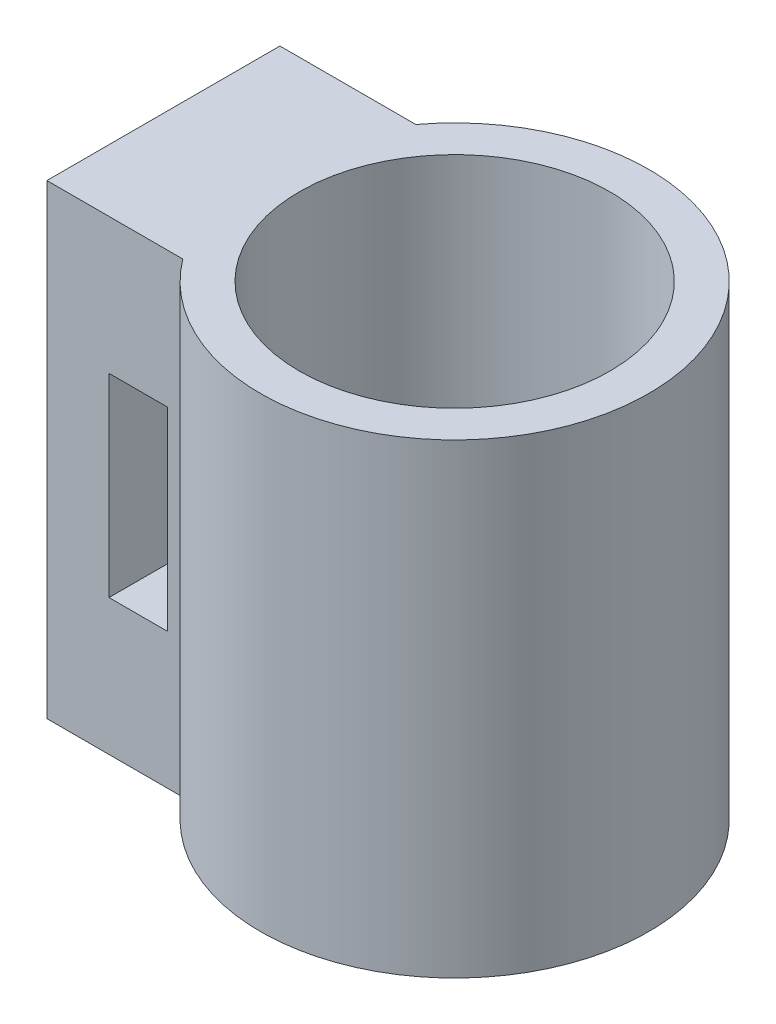
from build123d import *

# Parameters (mm, degrees)
BOSS_EXTRUDE1_DEPTH      = 6
BOSS_EXTRUDE1_DEPTH_BACK = 6
SKETCH1_R                = 4
SKETCH2_W                = 1.5
SKETCH2_H                = 5
CUT_EXTRUDE1_DEPTH       = 13.5


with BuildPart() as part:
    # Sketch1 → Boss-Extrude1 (new, two sides: drawn at the far end of the back side and taken through both)
    with BuildSketch(Plane(origin=(0, 0, 0), x_dir=(1, 0, 0), z_dir=(0, 1, 0)).offset(-BOSS_EXTRUDE1_DEPTH_BACK)):
        with BuildLine():
            Line((-4, 3), (-7.5, 3))
            Line((-7.5, 3), (-7.5, -3))
            Line((-7.5, -3), (-4, -3))
            ThreePointArc((-4, -3), (5, 0), (-4, 3))
        make_face()
        Circle(SKETCH1_R, mode=Mode.SUBTRACT)
    extrude(amount=BOSS_EXTRUDE1_DEPTH + BOSS_EXTRUDE1_DEPTH_BACK)

    # Sketch2 → Cut-Extrude1 (cut, through all)
    with BuildSketch(Plane(origin=(0, 0, -3), x_dir=(-1, 0, 0), z_dir=(0, 0, -1))):
        with Locations((5.15, 0)):
            Rectangle(SKETCH2_W, SKETCH2_H)
    extrude(amount=-CUT_EXTRUDE1_DEPTH, mode=Mode.SUBTRACT)


solid = part.part
